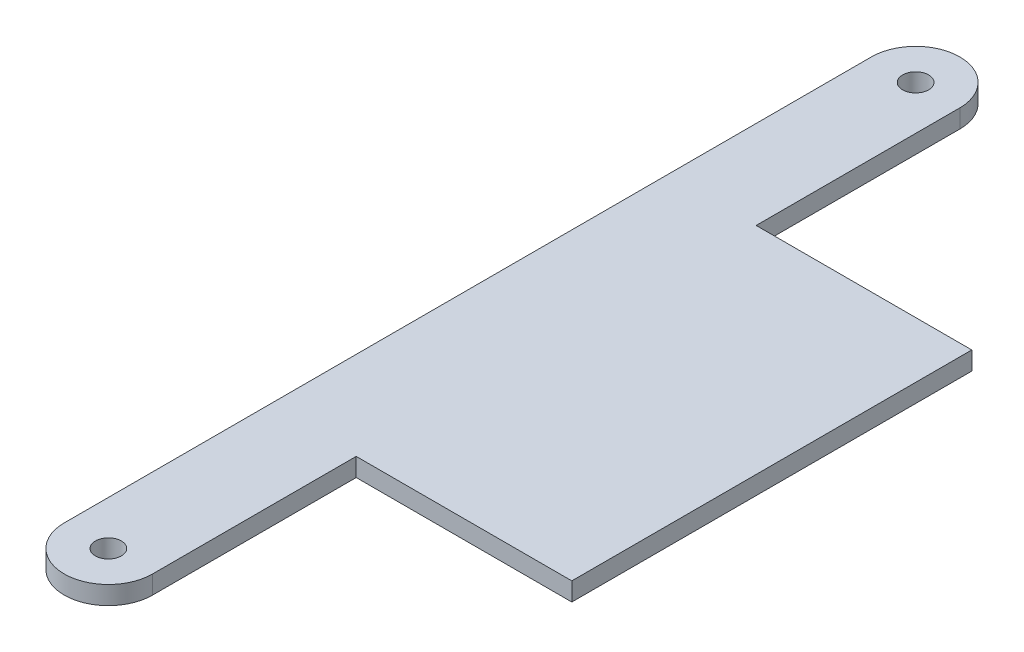
from build123d import *

# Parameters (mm, degrees)
SKETCH_W                  = 37.3126
SKETCH_H                  = 69.215
CORE_HOLDER_PLATE_F_DEPTH = 3.175
F_8_CLEARANCE_HOLE2_D     = 4.4958


with BuildPart() as part:
    # Sketch → CORE_HOLDER_PLATE-F (new body)
    with BuildSketch(Plane(origin=(0, 35.89274, 0), x_dir=(1, 0, 0), z_dir=(0, 1, 0))):
        with BuildLine():
            Line((7.6454, 69.85), (7.6454, -69.85))
            ThreePointArc((7.6454, -69.85), (0, -77.4954), (-7.6454, -69.85))
            Line((-7.6454, -69.85), (-7.6454, 69.85))
            ThreePointArc((-7.6454, 69.85), (0, 77.4954), (7.6454, 69.85))
        make_face()
        with Locations((26.3017, 0)):
            Rectangle(SKETCH_W, SKETCH_H)
    extrude(amount=CORE_HOLDER_PLATE_F_DEPTH)

    # #8 Clearance Hole2 (through all)
    with Locations(Plane.XZ.offset(-35.89274)):
        with Locations((0, 69.85), (0, -69.85)):
            Hole(F_8_CLEARANCE_HOLE2_D / 2)


solid = part.part
